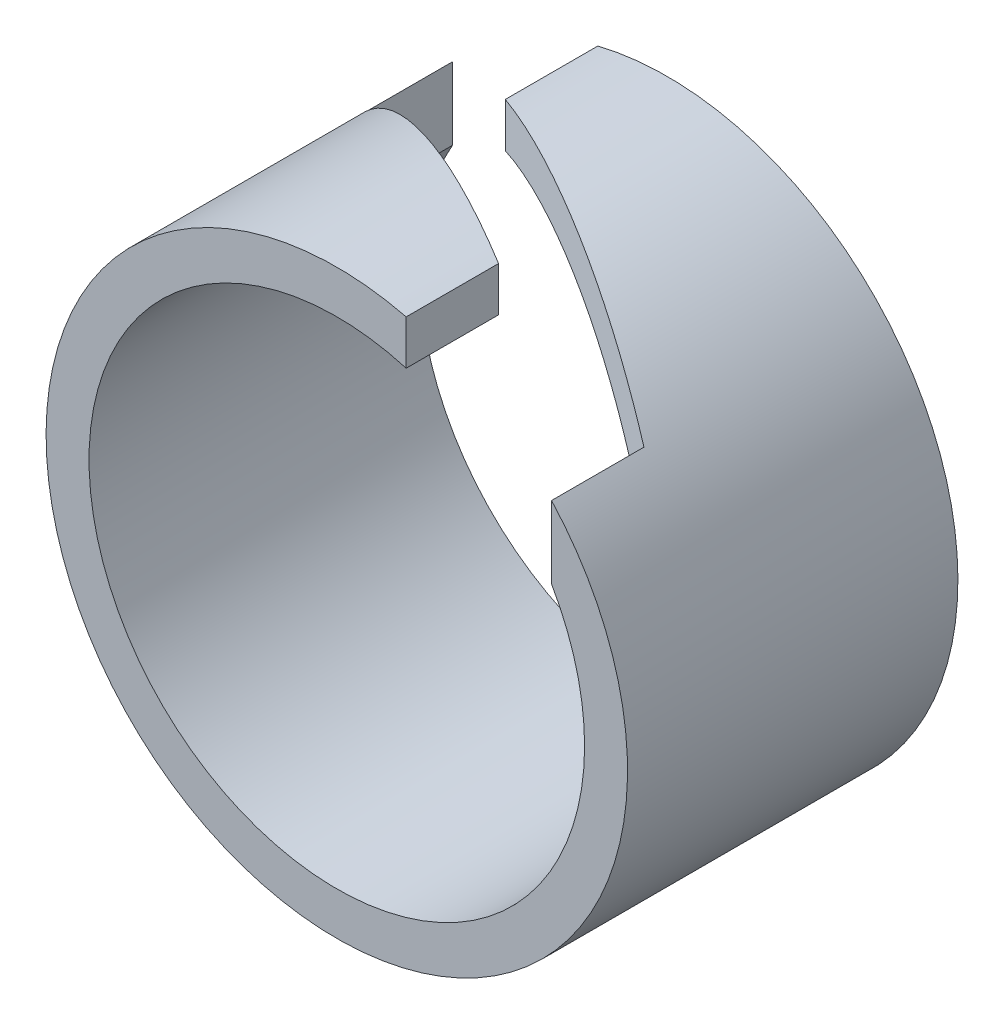
from build123d import *

# Parameters (mm, degrees)
SKETCH2_R           = 4.4
SKETCH2_R_2         = 3.75
BOSS_EXTRUDE1_DEPTH = 5
CUT_EXTRUDE1_DEPTH  = 5


with BuildPart() as part:
    # Sketch2 → Boss-Extrude1 (new body)
    with BuildSketch(Plane.XY):
        Circle(SKETCH2_R)
        Circle(SKETCH2_R_2, mode=Mode.SUBTRACT)
    extrude(amount=BOSS_EXTRUDE1_DEPTH)

    # Sketch3 → Cut-Extrude1 (cut)
    with BuildSketch(Plane(origin=(0, 4.4, 0), x_dir=(1, 0, 0), z_dir=(0, 1, 0))):
        Polygon((1.05, -5), (3.25, -5), (3.25, -3.60176001), (-1.05, -1.4), (-1.05, 0), (-3.25, 0), (-3.25, -1.4), (1.05, -3.60176001), align=None)
    extrude(amount=-CUT_EXTRUDE1_DEPTH, mode=Mode.SUBTRACT)


solid = part.part
